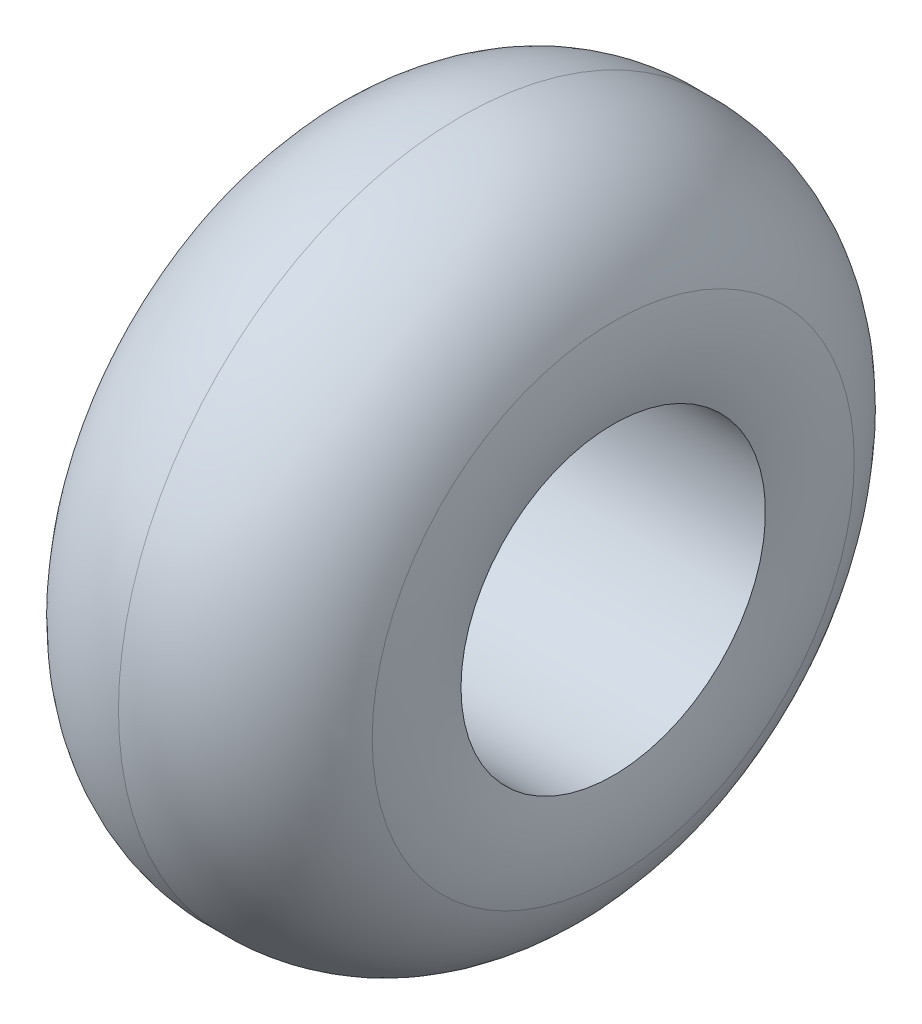
from build123d import *


with BuildPart() as part:
    # Sketch1 → Revolve1 (revolve)
    with BuildSketch(Plane.XY):
        with BuildLine():
            Line((-76.2, 76.2), (76.2, 76.2))
            ThreePointArc((76.2, 76.2), (79.15605032, 98.425), (76.2, 120.65))
            ThreePointArc((76.2, 120.65), (46.582996627, 158.77449494), (0, 171.45))
            ThreePointArc((0, 171.45), (-46.582996627, 158.77449494), (-76.2, 120.65))
            ThreePointArc((-76.2, 120.65), (-80.212253578, 98.425), (-76.2, 76.2))
        make_face()
    revolve(axis=Axis((0, 0, 0), (1, 0, 0)))


solid = part.part
